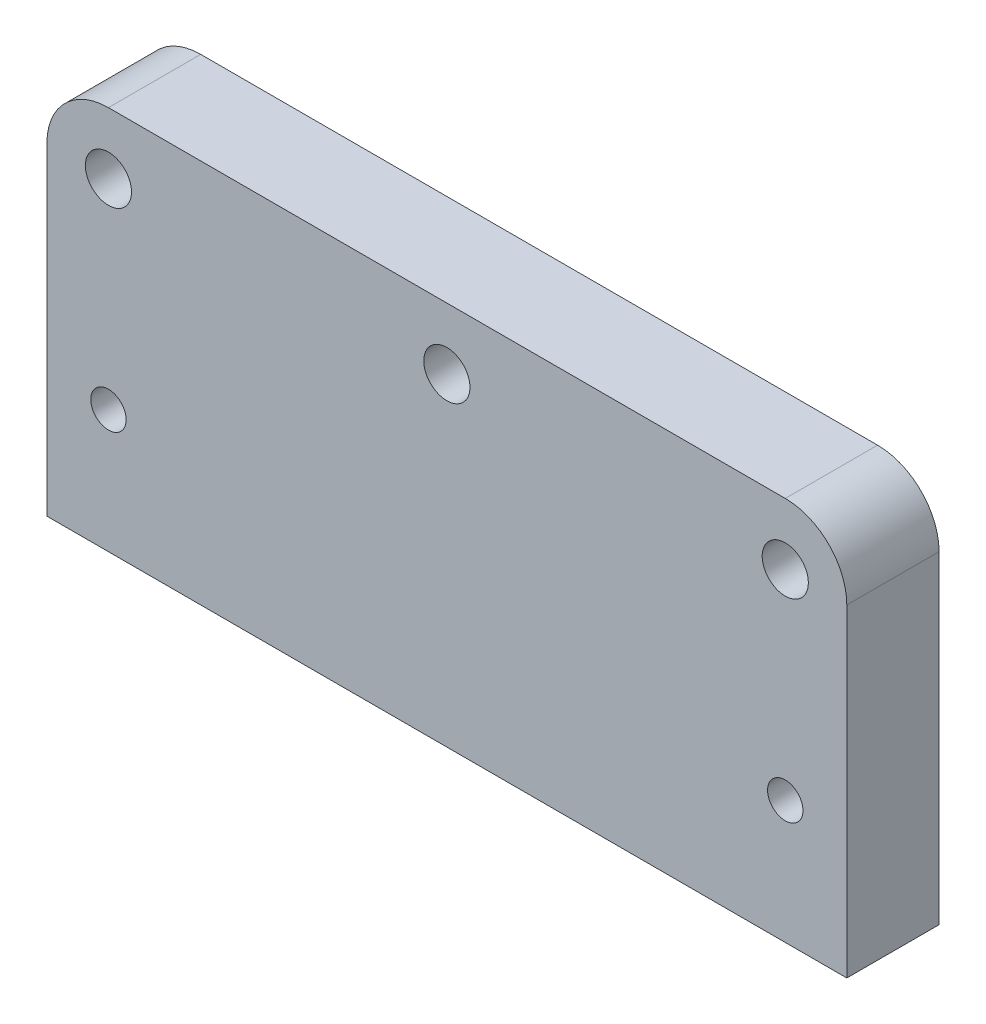
from build123d import *

# Parameters (mm, degrees)
SKETCH1_R           = 1.5
SKETCH1_R_2         = 1.15
BOSS_EXTRUDE1_DEPTH = 6


with BuildPart() as part:
    # Sketch1 → Boss-Extrude1 (new body)
    with BuildSketch(Plane.XY):
        with BuildLine():
            Line((0, 0), (52, 0))
            Line((52, 0), (52, 21))
            ThreePointArc((52, 21), (50.828427125, 23.828427125), (48, 25))
            Line((48, 25), (4, 25))
            ThreePointArc((4, 25), (1.171572875, 23.828427125), (0, 21))
            Line((0, 21), (0, 0))
        make_face()
        with Locations((4, 21)):
            Circle(SKETCH1_R, mode=Mode.SUBTRACT)
        with Locations((48, 21)):
            Circle(SKETCH1_R, mode=Mode.SUBTRACT)
        with Locations((4, 8)):
            Circle(SKETCH1_R_2, mode=Mode.SUBTRACT)
        with Locations((48, 8)):
            Circle(SKETCH1_R_2, mode=Mode.SUBTRACT)
        with Locations((26, 21)):
            Circle(SKETCH1_R, mode=Mode.SUBTRACT)
    extrude(amount=BOSS_EXTRUDE1_DEPTH)


solid = part.part
